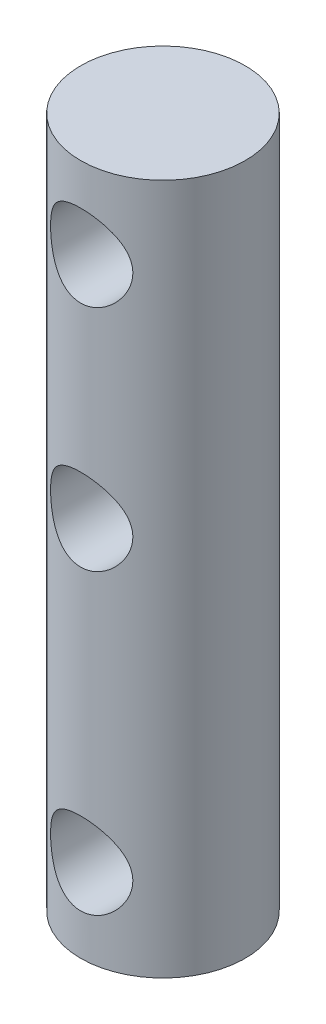
from build123d import *

# Parameters (mm, degrees)
SKETCH1_R               = 2.5
BOSS_EXTRUDE1_DEPTH     = 21
SKETCH2_R               = 1.25
CUT_EXTRUDE1_DEPTH      = 3.5
CUT_EXTRUDE1_DEPTH_BACK = 3.5


with BuildPart() as part:
    # Sketch1 → Boss-Extrude1 (new body)
    with BuildSketch(Plane(origin=(0, 0, 0), x_dir=(1, 0, 0), z_dir=(0, 1, 0))):
        Circle(SKETCH1_R)
    extrude(amount=BOSS_EXTRUDE1_DEPTH)

    # Sketch2 → Cut-Extrude1 (cut, two sides)
    with BuildSketch(Plane.XY) as cut_extrude1_sk:
        with Locations((0, 18.5)):
            Circle(SKETCH2_R)
        with Locations((0, 2.5)):
            Circle(SKETCH2_R)
        with Locations((0, 11.55)):
            Circle(SKETCH2_R)
    extrude(amount=CUT_EXTRUDE1_DEPTH, mode=Mode.SUBTRACT)
    extrude(cut_extrude1_sk.sketch, amount=-CUT_EXTRUDE1_DEPTH_BACK, mode=Mode.SUBTRACT)


solid = part.part
